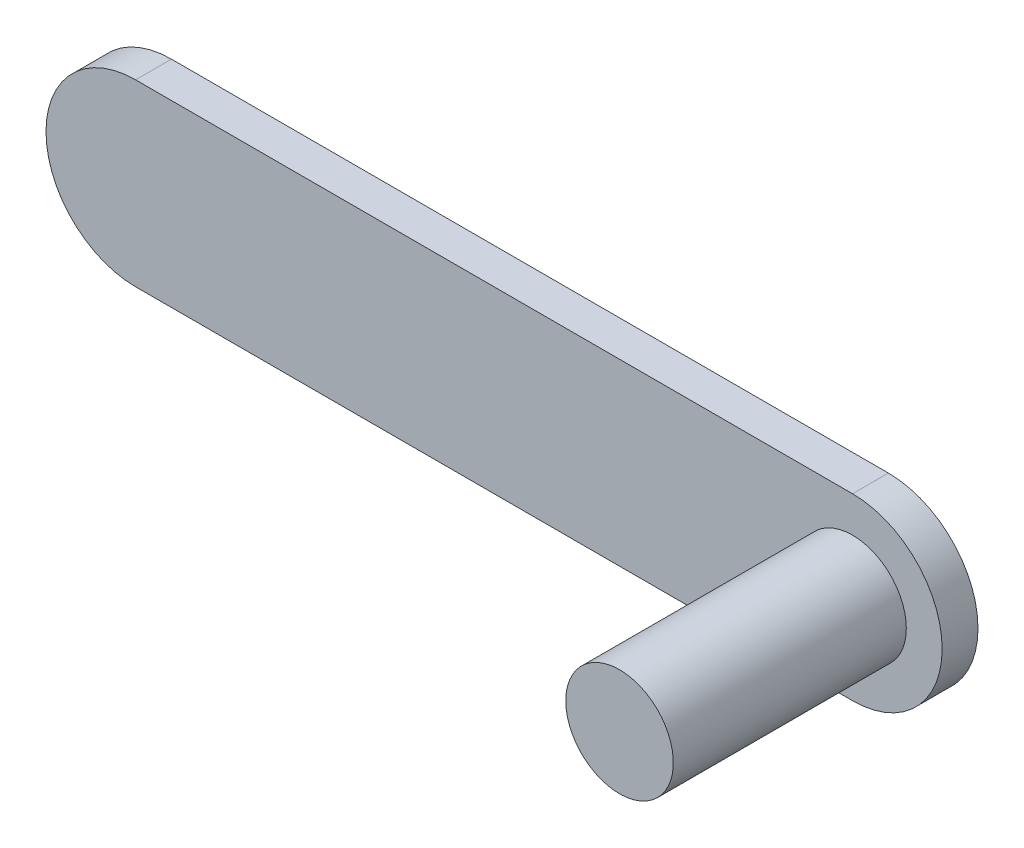
from build123d import *

# Parameters (mm, degrees)
EXTRUDE_1_DEPTH = 2
SKETCH_2_R      = 2
EXTRUDE_2_DEPTH = 2
SKETCH_3_R      = 3
EXTRUDE_4_DEPTH = 15


with BuildPart() as part:
    # 草图1 → 凸台-拉伸1 (new body)
    with BuildSketch(Plane.XY):
        with BuildLine():
            Line((-25, 5), (15, 5))
            ThreePointArc((15, 5), (20, 0), (15, -5))
            Line((15, -5), (-25, -5))
            ThreePointArc((-25, -5), (-30, 0), (-25, 5))
        make_face()
    extrude(amount=EXTRUDE_1_DEPTH)

    # 草图2 → 凸台-拉伸2 (add)
    with BuildSketch(Plane(origin=(0, 0, 0), x_dir=(-1, 0, 0), z_dir=(0, 0, -1))):
        with Locations((25, 0)):
            Circle(SKETCH_2_R)
    extrude(amount=EXTRUDE_2_DEPTH)

    # 草图3 → 凸台-拉伸4 (add)
    with BuildSketch(Plane(origin=(0, 0, 0), x_dir=(-1, 0, 0), z_dir=(0, 0, -1))):
        with Locations((-15, 0)):
            Circle(SKETCH_3_R)
    extrude(amount=-EXTRUDE_4_DEPTH)


solid = part.part
